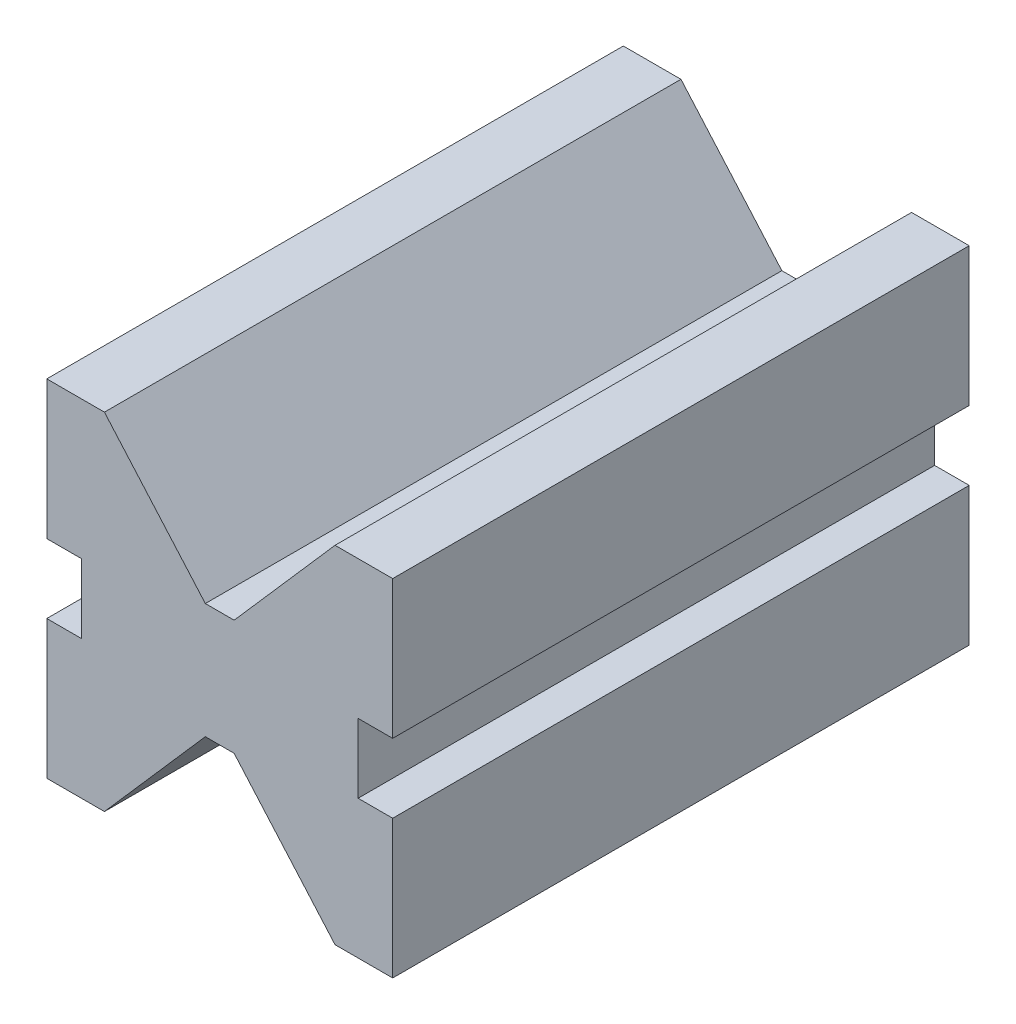
from build123d import *

# Parameters (mm, degrees)
Y_KSEKLIK_EKSTR_ZYON1_DEPTH = 100


with BuildPart() as part:
    # Çizim1 → Yükseklik-Ekstrüzyon1 (new body)
    with BuildSketch(Plane.XY):
        Polygon((0, 0), (10, 0), (27.5, 20), (32.5, 20), (50, 0), (60, 0), (60, 24), (54, 24), (54, 36), (60, 36), (60, 60), (50, 60), (32.5, 40), (27.5, 40), (10, 60), (0, 60), (0, 36), (6, 36), (6, 24), (0, 24), align=None)
    extrude(amount=Y_KSEKLIK_EKSTR_ZYON1_DEPTH)


solid = part.part
